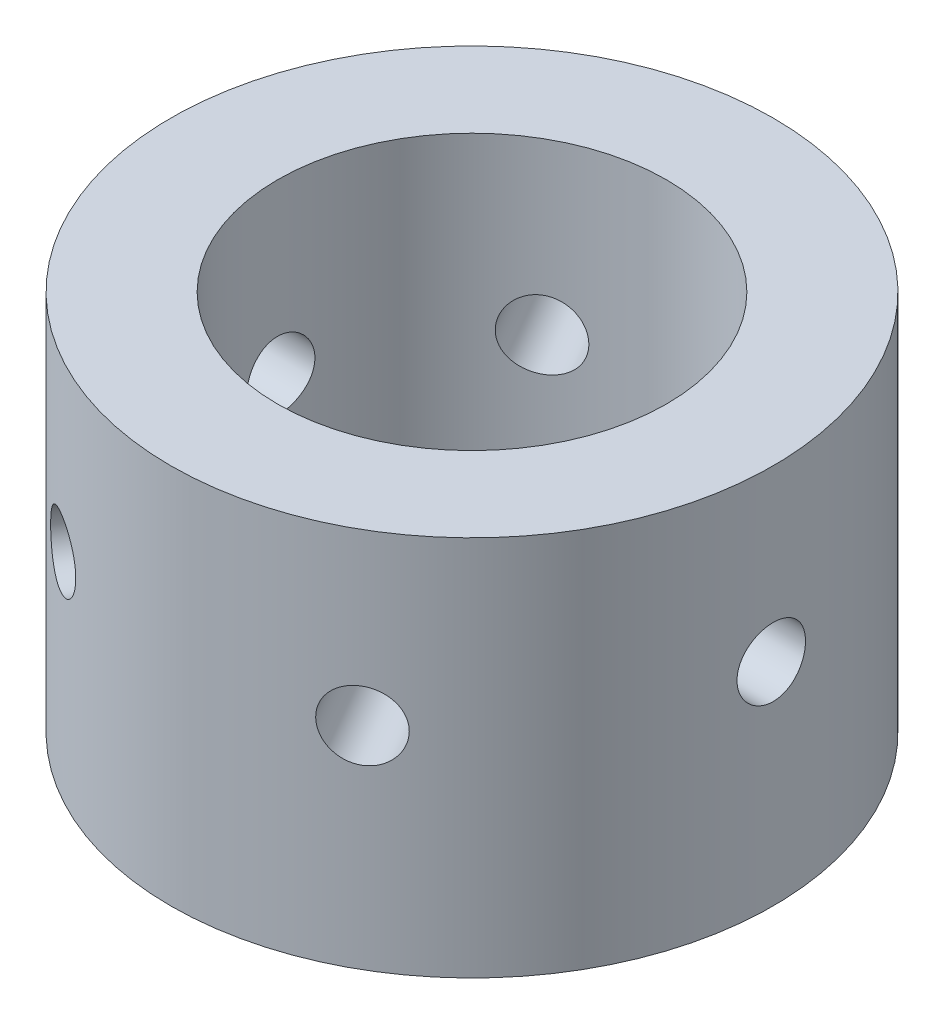
from build123d import *

# Parameters (mm, degrees)
SKETCH2_W                    = 12.3776613
SKETCH2_H                    = 44.1706
F_3_8_16_TAPPED_HOLE2_REACH  = 91.671
F_3_8_16_TAPPED_HOLE2_BORE_R = 3.96875
CIRPATTERN1_COUNT            = 6


with BuildPart() as part:
    # Sketch2 → Revolve1 (revolve)
    with BuildSketch(Plane.XY, mode=Mode.PRIVATE) as revolve1_sk:
        with Locations((-28.71076935, 22.0853)):
            Rectangle(SKETCH2_W, SKETCH2_H)
    revolve(revolve1_sk.sketch.rotate(Axis((0, 0, 0), (0, 1, 0)), 270), axis=Axis((0, 0, 0), (0, 1, 0)))

    # 3_8-16 Tapped Hole2 bore → 3_8-16 Tapped Hole2 (cut, up to next)
    with BuildSketch(Plane(origin=(34.8996, 0, 0), x_dir=(0, 0, -1), z_dir=(1, 0, 0)), mode=Mode.PRIVATE) as f_3_8_16_tapped_hole2_sk1:
        with Locations((0, 24.4856)):
            Circle(F_3_8_16_TAPPED_HOLE2_BORE_R)
    f_3_8_16_tapped_hole2_tool1 = extrude(f_3_8_16_tapped_hole2_sk1.sketch, amount=-F_3_8_16_TAPPED_HOLE2_REACH, mode=Mode.PRIVATE) & part.part
    f_3_8_16_tapped_hole2 = f_3_8_16_tapped_hole2_tool1.solids().sort_by_distance((34.8996, 24.4856, 0))[0]
    add(f_3_8_16_tapped_hole2, mode=Mode.SUBTRACT)

    # CirPattern1: 3_8-16 Tapped Hole2 ×6 about axis
    cirpattern1_axis = Axis((0, 44.1706, 0), (0, -1, 0))
    for i in range(1, CIRPATTERN1_COUNT):
        add(f_3_8_16_tapped_hole2.rotate(cirpattern1_axis, i * 360 / CIRPATTERN1_COUNT), mode=Mode.SUBTRACT)


solid = part.part
